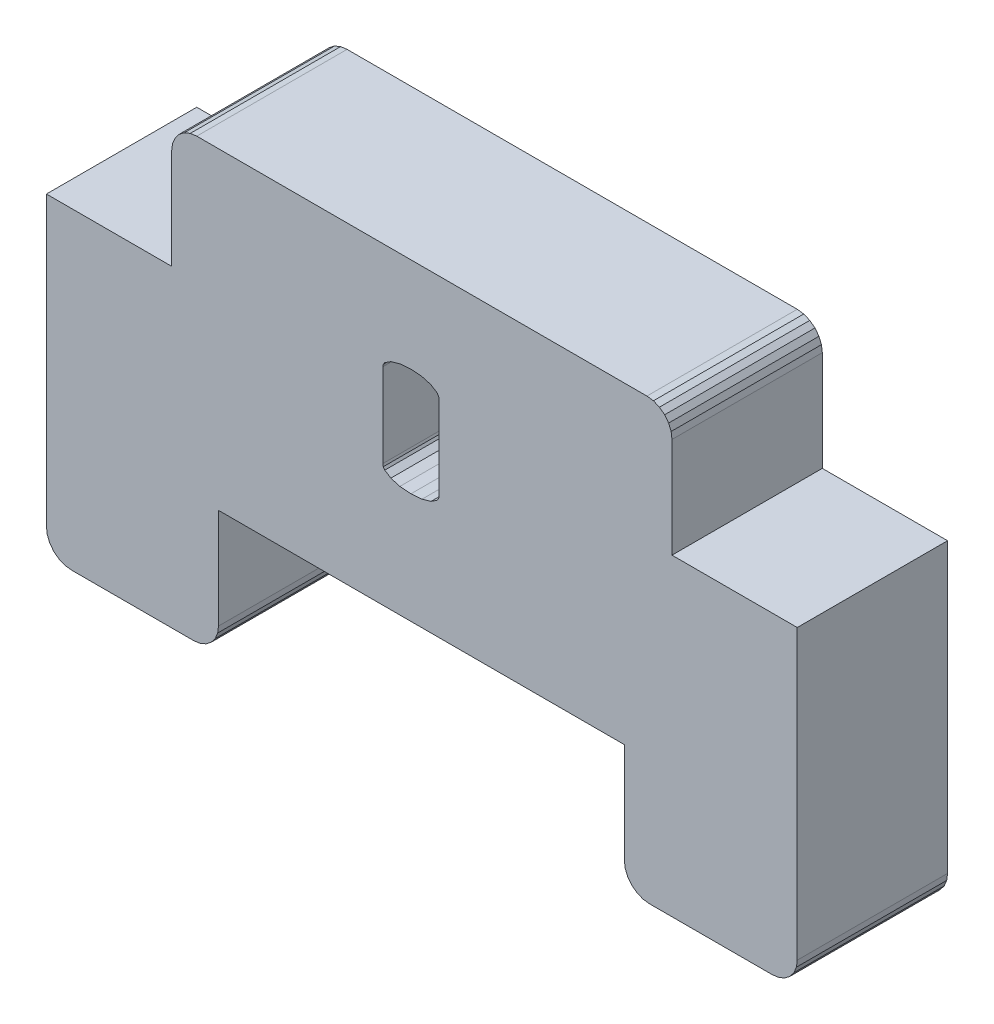
from build123d import *

# Parameters (mm, degrees)
BOSS_EXTRUDE1_DEPTH = 6


with BuildPart() as part:
    # Sketch1 → Boss-Extrude1 (new body)
    with BuildSketch(Plane.XY):
        Polygon((-339.62713504, -185.595121869), (-339.527234617, -185.836302824), (-339.368315994, -186.043409605), (-339.161209213, -186.202328228), (-338.920028258, -186.30222865), (-338.661209213, -186.336302824), (-333.761209213, -186.336302824), (-333.502390168, -186.30222865), (-333.261209213, -186.202328228), (-333.054102432, -186.043409605), (-332.89518381, -185.836302824), (-332.795283387, -185.595121869), (-332.761209213, -185.336302824), (-332.761209213, -173.836302824), (-337.761209213, -173.836302824), (-337.761209213, -169.836302824), (-337.795283387, -169.577483779), (-337.89518381, -169.336302824), (-338.054102432, -169.129196043), (-338.261209213, -168.97027742), (-338.502390168, -168.870376998), (-338.761209213, -168.836302824), (-356.729668375, -168.836302824), (-356.98848742, -168.870376998), (-357.229668375, -168.97027742), (-357.436775156, -169.129196043), (-357.595693779, -169.336302824), (-357.695594201, -169.577483779), (-357.729668375, -169.836302824), (-357.729668375, -173.836302824), (-362.729668375, -173.836302824), (-362.729668375, -185.336302824), (-362.695594201, -185.595121869), (-362.595693779, -185.836302824), (-362.436775156, -186.043409605), (-362.229668375, -186.202328228), (-361.98848742, -186.30222865), (-361.729668375, -186.336302824), (-356.861204217, -186.336302824), (-356.602385172, -186.30222865), (-356.361204217, -186.202328228), (-356.154097436, -186.043409605), (-355.995178813, -185.836302824), (-355.895278391, -185.595121869), (-355.861204217, -185.336302824), (-355.861204217, -181.336302824), (-339.661209213, -181.336302824), (-339.661209213, -185.336302824), align=None)
        Polygon((-349.304475558, -176.444049414), (-349.284378617, -176.540258684), (-349.224087791, -176.629048461), (-348.982924491, -176.784369536), (-348.621560638, -176.889731102), (-348.180571214, -176.924851625), (-347.739581789, -176.889731102), (-347.378217936, -176.784369536), (-347.137054636, -176.629048461), (-347.076763811, -176.540258684), (-347.056666869, -176.444049414), (-347.056666869, -173.097345908), (-347.076763811, -173.001155991), (-347.137054636, -172.912376634), (-347.378217936, -172.757049605), (-347.739581789, -172.651670175), (-348.180571214, -172.616543698), (-348.621560638, -172.651670175), (-348.982924491, -172.757049605), (-349.224087791, -172.912376634), (-349.284378617, -173.001155991), (-349.304475558, -173.097345908), align=None, mode=Mode.SUBTRACT)
    extrude(amount=BOSS_EXTRUDE1_DEPTH)


solid = part.part
